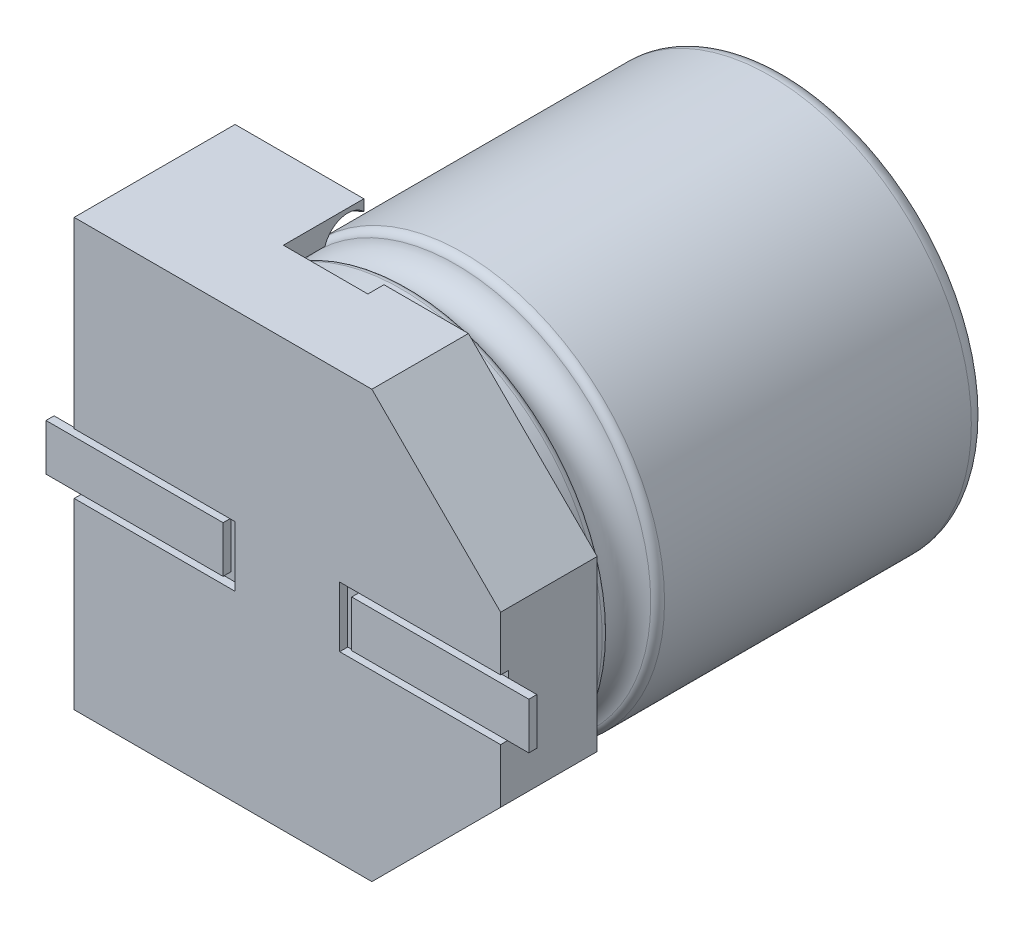
from build123d import *

# Parameters (mm, degrees)
DODANIE_WYCI_GNI_CIE1_DEPTH   = 2
SZKIC2_W                      = 2
SZKIC2_H                      = 0.75
DODANIE_WYCI_GNI_CIE2_DEPTH   = 1.9
SZKIC3_W                      = 2.200379753
SZKIC3_H                      = 0.577969806
DODANIE_WYCI_GNI_CIE3_DEPTH   = 0.1
DODANIE_WYCI_GNI_CIE3_2_DEPTH = 0.1
WYTNIJ_WYCI_GNI_CIE1_DEPTH    = 1
WYTNIJ_WYCI_GNI_CIE2_DEPTH    = 0.8
SZKIC6_R                      = 2.5
DODANIE_WYCI_GNI_CIE4_DEPTH   = 5.2
ZAOKR_GLENIE1_R               = 0.2
SZKIC9_R                      = 0.3
ZAOKR_GLENIE2_R               = 0.1


with BuildPart() as part:
    # Szkic1 → Dodanie-wyciągnięcie1 (new body)
    with BuildSketch(Plane.XY):
        Polygon((2.65, -1.05), (2.65, -0.375), (0.65, -0.375), (0.65, 0.375), (2.65, 0.375), (2.65, 1.05), (1.05, 2.65), (-2.65, 2.65), (-2.65, 0.375), (-0.65, 0.375), (-0.65, -0.375), (-2.65, -0.375), (-2.65, -2.65), (1.05, -2.65), align=None)
    extrude(amount=DODANIE_WYCI_GNI_CIE1_DEPTH)

    # Szkic2 → Dodanie-wyciągnięcie2 (add)
    with BuildSketch(Plane(origin=(0, 0, 0), x_dir=(-1, 0, 0), z_dir=(0, 0, -1))):
        with Locations((-1.65, 0)):
            Rectangle(SZKIC2_W, SZKIC2_H)
        with Locations((1.65, 0)):
            Rectangle(SZKIC2_W, SZKIC2_H)
    extrude(amount=-DODANIE_WYCI_GNI_CIE2_DEPTH)

    # Szkic4 → Wytnij-wyciągnięcie1 (cut)
    with BuildSketch(Plane(origin=(0, 0, 0), x_dir=(-1, 0, 0), z_dir=(0, 0, -1))):
        with BuildLine():
            Line((1.05, 2.65), (0, 2.65))
            Line((0, 2.65), (0, 2.6))
            ThreePointArc((0, 2.6), (-2.6, 0), (0, -2.6))
            Line((0, -2.6), (0, -2.65))
            Line((0, -2.65), (1.05, -2.65))
            Line((1.05, -2.65), (1.05, -2.378549978))
            ThreePointArc((1.05, -2.378549978), (1.838477631, -1.838477631), (2.378549978, -1.05))
            Line((2.378549978, -1.05), (2.65, -1.05))
            Line((2.65, -1.05), (2.65, 1.05))
            Line((2.65, 1.05), (2.378549978, 1.05))
            ThreePointArc((2.378549978, 1.05), (1.838477631, 1.838477631), (1.05, 2.378549978))
            Line((1.05, 2.378549978), (1.05, 2.65))
        make_face()
    extrude(amount=-WYTNIJ_WYCI_GNI_CIE1_DEPTH, mode=Mode.SUBTRACT)

    # Szkic5 → Wytnij-wyciągnięcie2 (cut)
    with BuildSketch(Plane(origin=(0, 0, 0), x_dir=(-1, 0, 0), z_dir=(0, 0, -1))):
        Polygon((0.494672593, 3.837977015), (0.494672593, -3.940323068), (-3.599169556, -3.326246746), (-6.226051601, 2.132209453), align=None)
    extrude(amount=-WYTNIJ_WYCI_GNI_CIE2_DEPTH, mode=Mode.SUBTRACT)


with BuildPart() as body_2:
    # Szkic3 → Dodanie-wyciągnięcie3 (new body)
    with BuildSketch(Plane.XY.offset(1.9)):
        with Locations((1.899810124, 0)):
            Rectangle(SZKIC3_W, SZKIC3_H)
    extrude(amount=DODANIE_WYCI_GNI_CIE3_DEPTH)


with BuildPart() as body_3:
    # Szkic3 → Dodanie-wyci_gni_cie3 2 (new body)
    with BuildSketch(Plane.XY.offset(1.9)):
        with Locations((-1.899810124, 0)):
            Rectangle(SZKIC3_W, SZKIC3_H)
    extrude(amount=DODANIE_WYCI_GNI_CIE3_2_DEPTH)


with BuildPart() as body_4:
    # Szkic6 → Dodanie-wyciągnięcie4 (new body)
    with BuildSketch(Plane(origin=(0, 0, 1), x_dir=(-1, 0, 0), z_dir=(0, 0, -1))):
        Circle(SZKIC6_R)
    extrude(amount=DODANIE_WYCI_GNI_CIE4_DEPTH)

    # Zaokrąglenie1
    zaokr_glenie1_edges = [body_4.edges().sort_by_distance(p)[0] for p in [
        (2.5, 0, -4.2),
    ]]
    fillet(zaokr_glenie1_edges, radius=ZAOKR_GLENIE1_R)


with BuildPart() as wyci_cie_obr_t1_tool:
    # Szkic9 → Wycięcie-obrót1 (revolve)
    with BuildSketch(Plane(origin=(0, 0, 0), x_dir=(1, 0, 0), z_dir=(0, 1, 0))):
        with Locations((2.5, -0.2)):
            Circle(SZKIC9_R)
    revolve(axis=Axis((0, 0, -4.2), (0, 0, 1)))


with BuildPart() as part_1:
    add(part.part)

    # Wycięcie-obrót1: cut by wyci_cie_obr_t1_tool
    add(wyci_cie_obr_t1_tool.part, mode=Mode.SUBTRACT)


with BuildPart() as body_4_1:
    add(body_4.part)

    # Wycięcie-obrót1: cut by wyci_cie_obr_t1_tool
    add(wyci_cie_obr_t1_tool.part, mode=Mode.SUBTRACT)

    # Zaokrąglenie2
    zaokr_glenie2_edges = [body_4_1.edges().sort_by_distance(p)[0] for p in [
        (0, -2.5, -0.1),
        (0, -2.5, 0.5),
    ]]
    fillet(zaokr_glenie2_edges, radius=ZAOKR_GLENIE2_R)


solid = Compound([body_2.part, body_3.part, part_1.part, body_4_1.part])
